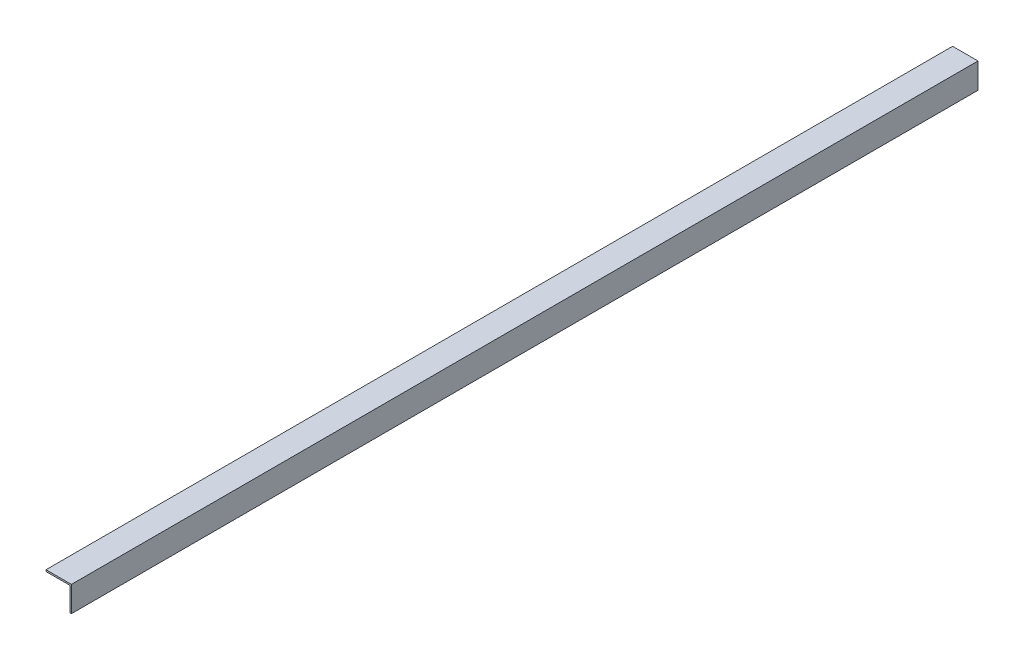
from build123d import *

# Parameters (mm, degrees)
BOSS_EXTRUDE1_DEPTH = 1812.925


with BuildPart() as part:
    # Sketch1 → Boss-Extrude1 (new body)
    with BuildSketch(Plane.XY):
        Polygon((0, 0), (-50.8, 0), (-50.8, -3.175), (-3.175, -3.175), (-3.175, -50.8), (0, -50.8), align=None)
    extrude(amount=BOSS_EXTRUDE1_DEPTH)


solid = part.part
